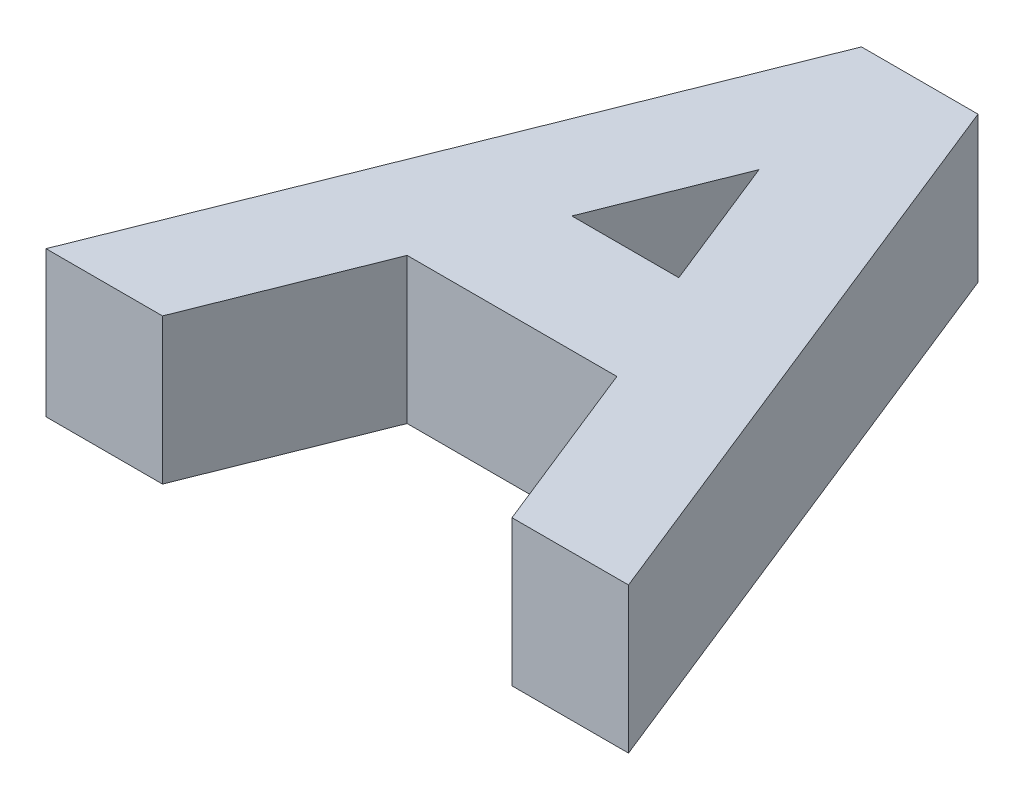
from build123d import *

# Parameters (mm, degrees)
BOSS_EXTRUDE1_DEPTH = 10


with BuildPart() as part:
    # Sketch1 → Boss-Extrude1 (new body)
    with BuildSketch(Plane(origin=(0, 0, 0), x_dir=(1, 0, 0), z_dir=(0, 1, 0))):
        Polygon((0, 0), (16, 40), (24, 40), (40, 0), (32, 0), (27.2, 12), (12.8, 12), (8, 0), align=None)
        Polygon((16.110598883, 20), (19.781948191, 29.17837327), (23.453297499, 20), align=None, mode=Mode.SUBTRACT)
    extrude(amount=BOSS_EXTRUDE1_DEPTH)


solid = part.part
